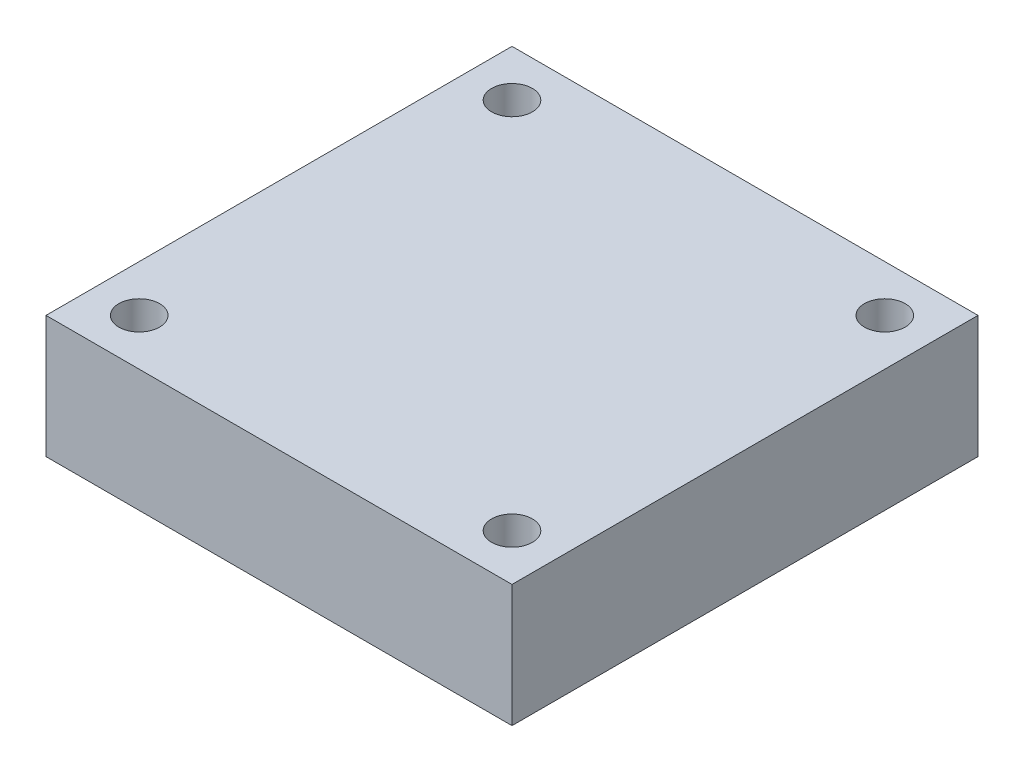
from build123d import *

# Parameters (mm, degrees)
SKETCH1_W           = 40
SKETCH1_H           = 40
BOSS_EXTRUDE1_DEPTH = 10.5
SKETCH2_R           = 1.75
CUT_EXTRUDE1_DEPTH  = 10.5


with BuildPart() as part:
    # Sketch1 → Boss-Extrude1 (new body)
    with BuildSketch(Plane(origin=(0, 0, 0), x_dir=(1, 0, 0), z_dir=(0, 1, 0))):
        Rectangle(SKETCH1_W, SKETCH1_H)
    extrude(amount=BOSS_EXTRUDE1_DEPTH)

    # Sketch2 → Cut-Extrude1 (cut)
    with BuildSketch(Plane(origin=(0, 10.5, 0), x_dir=(1, 0, 0), z_dir=(0, 1, 0))):
        with Locations((-16, 16)):
            Circle(SKETCH2_R)
        with Locations((16, 16)):
            Circle(SKETCH2_R)
        with Locations((16, -16)):
            Circle(SKETCH2_R)
        with Locations((-16, -16)):
            Circle(SKETCH2_R)
    extrude(amount=-CUT_EXTRUDE1_DEPTH, mode=Mode.SUBTRACT)


solid = part.part
